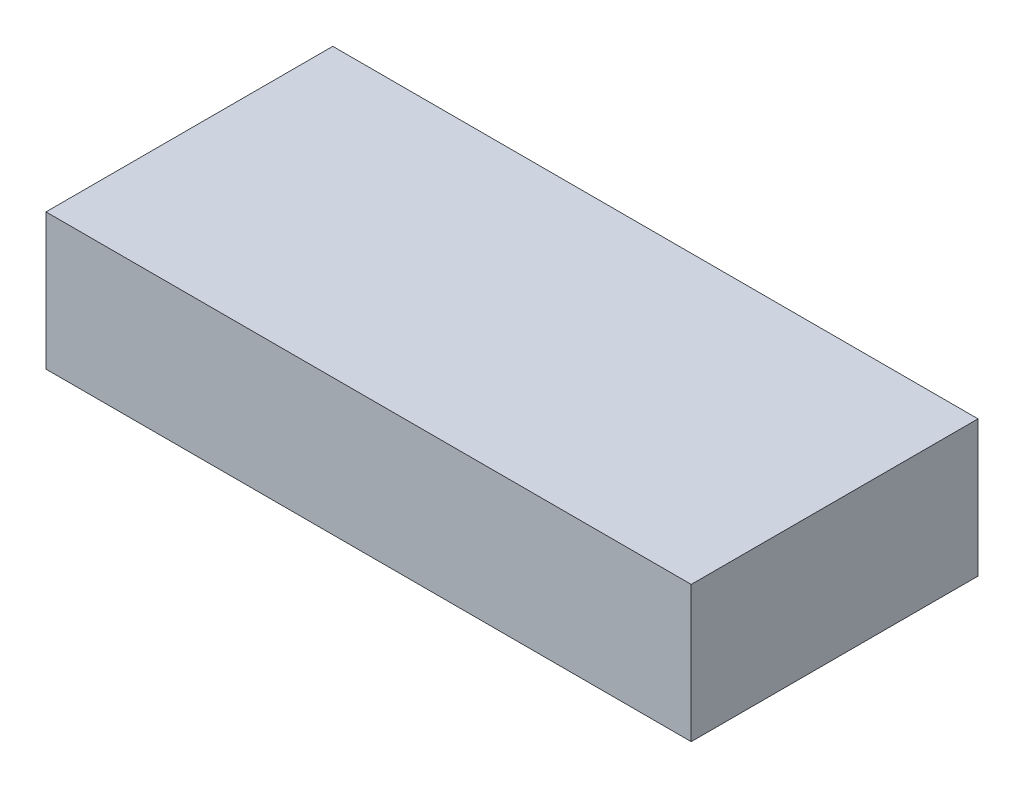
from build123d import *

# Parameters (mm, degrees)
SKETCH1_W           = 90
SKETCH1_H           = 40
BOSS_EXTRUDE1_DEPTH = 19


with BuildPart() as part:
    # Sketch1 → Boss-Extrude1 (new body)
    with BuildSketch(Plane(origin=(0, 0, 0), x_dir=(1, 0, 0), z_dir=(0, 1, 0))):
        with Locations((45, 20)):
            Rectangle(SKETCH1_W, SKETCH1_H)
    extrude(amount=BOSS_EXTRUDE1_DEPTH)


solid = part.part
